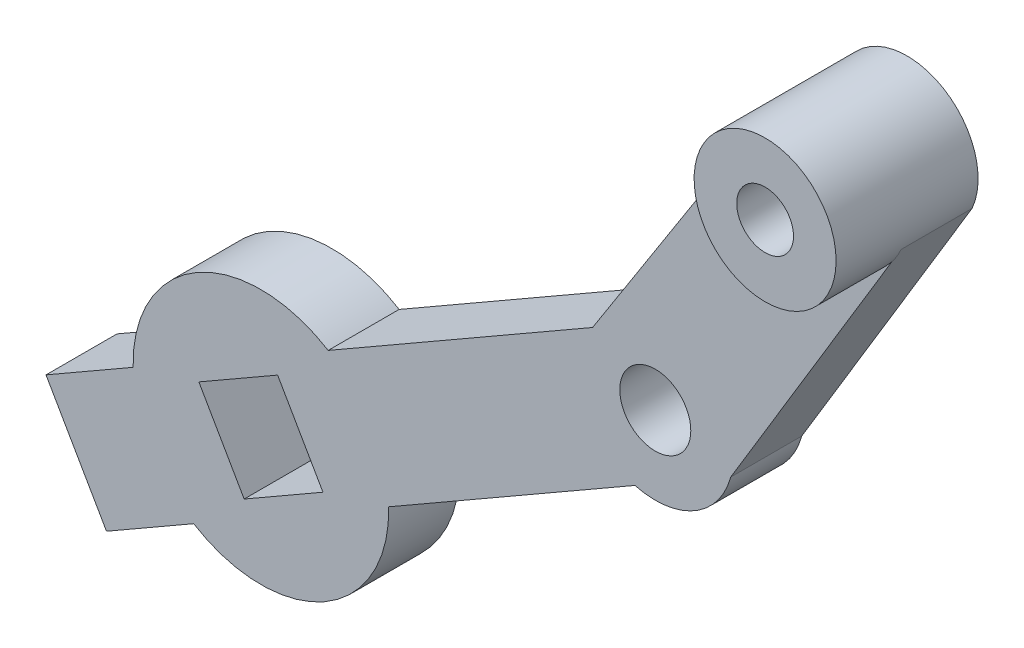
from build123d import *

# Parameters (mm, degrees)
SKETCH1_R           = 2
SKETCH1_R_2         = 2.5
BOSS_EXTRUDE1_DEPTH = 5
SKETCH6_R           = 9
BOSS_EXTRUDE3_DEPTH = 5
CUT_EXTRUDE1_REACH  = 7
SKETCH13_R          = 1
CUT_EXTRUDE2_DEPTH  = 0.5
SKETCH14_R          = 5
SKETCH14_R_2        = 2
BOSS_EXTRUDE4_DEPTH = 5


with BuildPart() as part:
    # Sketch1 → Boss-Extrude1 (new body)
    with BuildSketch(Plane(origin=(0, 0, 0), x_dir=(0.498528904, -0.866873077, 0), z_dir=(0, 0, 1))):
        with BuildLine():
            Line((8.899126574, 3.869128256), (-2.35642803, 24.179978159))
            ThreePointArc((-2.35642803, 24.179978159), (-9.345167797, 25.255857552), (-10.421047189, 18.267117784))
            Line((-10.421047189, 18.267117784), (1.120951981, -3.909046337))
            ThreePointArc((1.120951981, -3.909046337), (8.899126574, -3.909046337), (8.899126574, 3.869128256))
        make_face()
        with Locations((-6.38873761, 21.223547972)):
            Circle(SKETCH1_R, mode=Mode.SUBTRACT)
        with Locations((5.010039278, -0.019959041)):
            Circle(SKETCH1_R_2, mode=Mode.SUBTRACT)
        with BuildLine():
            Line((8.899126574, -46.838046337), (8.899126574, -3.909046337))
            ThreePointArc((8.899126574, -3.909046337), (5.010039278, -5.519959041), (1.120951981, -3.909046337))
            Line((1.120951981, -3.909046337), (0.353553391, -2.434608777))
            Line((0.353553391, -2.434608777), (0.353553391, -46.838046337))
            Line((0.353553391, -46.838046337), (8.899126574, -46.838046337))
        make_face()
    extrude(amount=BOSS_EXTRUDE1_DEPTH)

    # Sketch6 → Boss-Extrude3 (add)
    with BuildSketch(Plane.XY.offset(5)):
        with Locations((-25.293181008, -19.882635909)):
            Circle(SKETCH6_R)
    extrude(amount=-BOSS_EXTRUDE3_DEPTH)

    # Sketch12 → Cut-Extrude1 (cut, up to next)
    with BuildSketch(Plane.XY.offset(5), mode=Mode.PRIVATE) as cut_extrude1_sk1:
        Polygon((-20.923894669, -21.061337265), (-24.114479652, -15.51334957), (-29.662467347, -18.703934553), (-26.471882365, -24.251922248), align=None)
    cut_extrude1_tool1 = extrude(cut_extrude1_sk1.sketch, amount=-CUT_EXTRUDE1_REACH, mode=Mode.PRIVATE) & part.part
    add(cut_extrude1_tool1.solids().sort_by_distance((-25.293181, -19.882636, 5))[0], mode=Mode.SUBTRACT)

    # Sketch13 → Cut-Extrude2 (cut)
    with BuildSketch(Plane(origin=(-24.825551359, -14.27689384, 0), x_dir=(0, 0, 1), z_dir=(-0.866873077, -0.498528904, 0))):
        with Locations((2.5, -4.626339983)):
            Circle(SKETCH13_R)
    extrude(amount=-CUT_EXTRUDE2_DEPTH, mode=Mode.SUBTRACT)

    # Sketch14 → Boss-Extrude4 (add)
    with BuildSketch(Plane.XY.offset(5)):
        with Locations((15.213151988, 16.118776732)):
            Circle(SKETCH14_R)
        with Locations((15.213151988, 16.118776732)):
            Circle(SKETCH14_R_2, mode=Mode.SUBTRACT)
    extrude(amount=BOSS_EXTRUDE4_DEPTH)


solid = part.part
